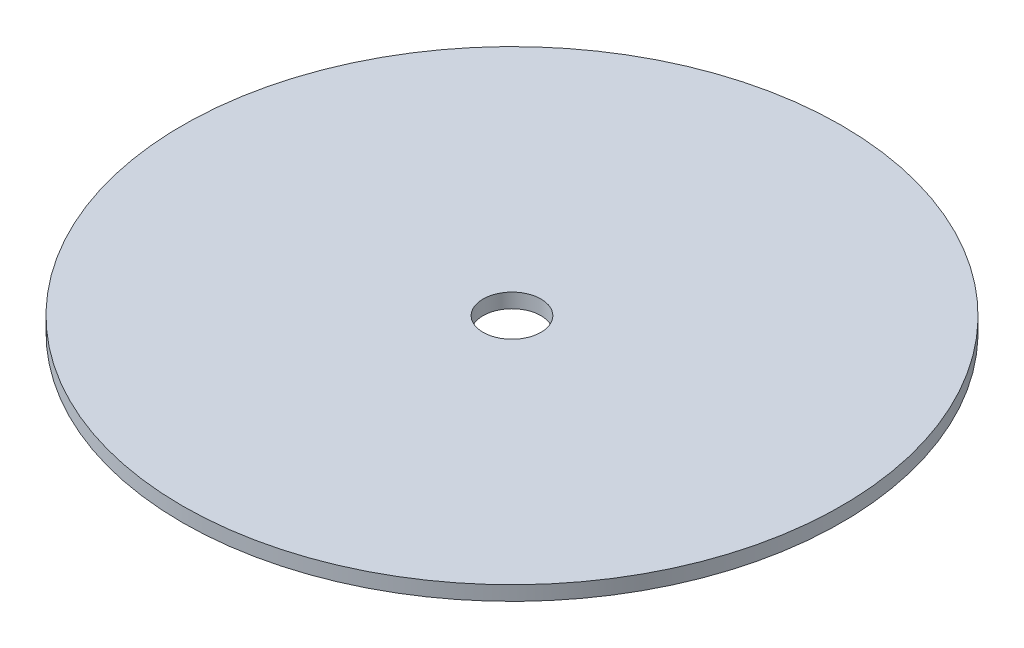
from build123d import *

# Parameters (mm, degrees)
SKETCH1_R           = 72.39
BOSS_EXTRUDE1_DEPTH = 3.175
SKETCH2_R           = 6.35
CUT_EXTRUDE1_DEPTH  = 4.175


with BuildPart() as part:
    # Sketch1 → Boss-Extrude1 (new body)
    with BuildSketch(Plane(origin=(0, 0, 0), x_dir=(1, 0, 0), z_dir=(0, 1, 0))):
        Circle(SKETCH1_R)
    extrude(amount=BOSS_EXTRUDE1_DEPTH)

    # Sketch2 → Cut-Extrude1 (cut, through all)
    with BuildSketch(Plane(origin=(0, 3.175, 0), x_dir=(1, 0, 0), z_dir=(0, 1, 0))):
        Circle(SKETCH2_R)
    extrude(amount=-CUT_EXTRUDE1_DEPTH, mode=Mode.SUBTRACT)


solid = part.part
